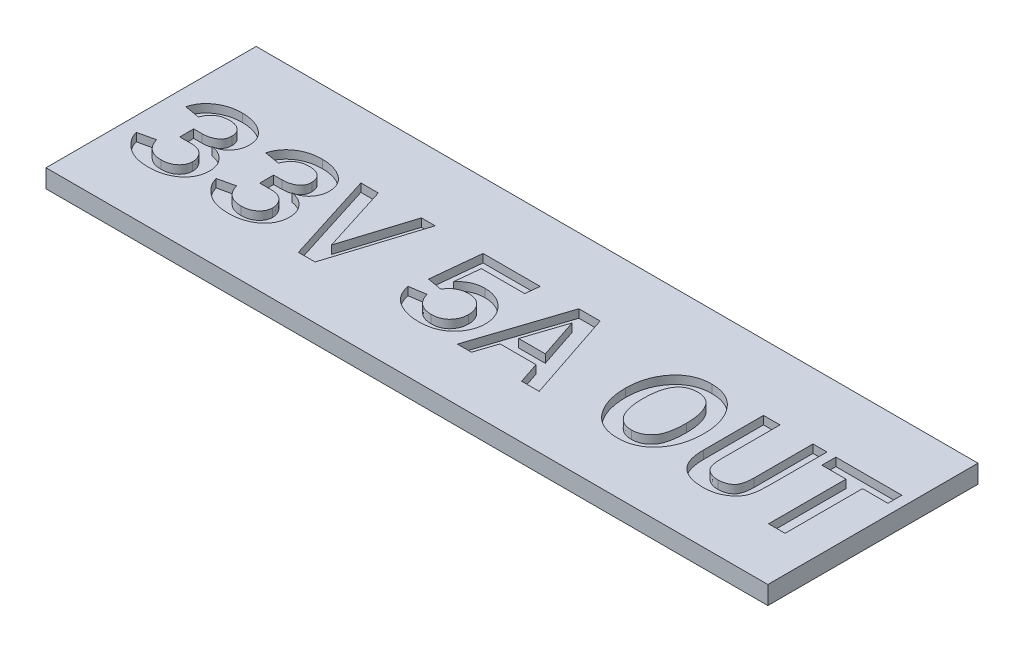
from build123d import *

# Parameters (mm, degrees)
SKETCH1_W           = 39.5
SKETCH1_H           = 11.5
BOSS_EXTRUDE1_DEPTH = 1
CUT_EXTRUDE1_DEPTH  = 0.45


with BuildPart() as part:
    # Sketch1 → Boss-Extrude1 (new body)
    with BuildSketch(Plane(origin=(0, 0, 0), x_dir=(1, 0, 0), z_dir=(0, 1, 0))):
        with Locations((6.224137931, 6.305172414)):
            Rectangle(SKETCH1_W, SKETCH1_H)
    extrude(amount=BOSS_EXTRUDE1_DEPTH)

    # Sketch2 → Cut-Extrude1 (cut)
    with BuildSketch(Plane(origin=(0, 1, 0), x_dir=(1, 0, 0), z_dir=(0, 1, 0))):
        with BuildLine():
            Line((-11.32600679, 5.673934363), (-11.32600679, 6.437823252))
            Line((-11.32600679, 6.437823252), (-10.877873109, 6.437823252))
            add(Edge.make_bspline(
                [(-10.877873109, 6.437823252), (-10.813316125, 6.439580263), (-10.689033154, 6.442962803), (-10.511370698, 6.477910683), (-10.349498962, 6.531465156), (-10.228160081, 6.595879397), (-10.142989777, 6.65863775), (-10.087086149, 6.710363239), (-10.040818181, 6.769236814), (-10.003182358, 6.832865086), (-9.973279085, 6.901728843), (-9.951278075, 6.975556434), (-9.939812107, 7.055593236), (-9.938032673, 7.110534094), (-9.937117901, 7.138778113)],
                knots=[0, 0, 0, 0, 0.000193447, 0.000372418, 0.000540897, 0.000703531, 0.000781874, 0.000857868, 0.000931244, 0.00100568, 0.001079057, 0.001155967, 0.001236071, 0.001320818, 0.001320818, 0.001320818, 0.001320818], degree=3))
            add(Edge.make_bspline(
                [(-9.937117901, 7.138778113), (-9.937606358, 7.166666113), (-9.93854931, 7.22050314), (-9.949700075, 7.298735949), (-9.968181506, 7.371382747), (-9.992913501, 7.439403529), (-10.025694734, 7.501871022), (-10.066276641, 7.558396604), (-10.113232361, 7.610255042), (-10.186752806, 7.670799996), (-10.291183551, 7.73529583), (-10.434049188, 7.787785268), (-10.592393334, 7.821357281), (-10.7037157, 7.824876734), (-10.761770679, 7.826712141)],
                knots=[0, 0, 0, 0, 8.3614e-05, 0.000161414, 0.000236417, 0.000308172, 0.000378064, 0.000447313, 0.000516435, 0.000587289, 0.000732445, 0.000882177, 0.001041782, 0.001215732, 0.001215732, 0.001215732, 0.001215732], degree=3))
            add(Edge.make_bspline(
                [(-10.761770679, 7.826712141), (-10.820523593, 7.824774438), (-10.934294399, 7.821022216), (-11.09756638, 7.788009334), (-11.246414463, 7.733502172), (-11.380688433, 7.656865866), (-11.499506359, 7.557227646), (-11.603368962, 7.436278146), (-11.692258586, 7.293328639), (-11.736903061, 7.187236761), (-11.760034568, 7.132267697)],
                knots=[0, 0, 0, 0, 0.000176116, 0.000341036, 0.000497244, 0.000649865, 0.000802409, 0.000960118, 0.001126318, 0.001305022, 0.001305022, 0.001305022, 0.001305022], degree=3))
            Line((-11.760034568, 7.132267697), (-12.593367901, 7.271156586))
            add(Edge.make_bspline(
                [(-12.593367901, 7.271156586), (-12.580924516, 7.316319519), (-12.556231345, 7.405942721), (-12.502741432, 7.534362043), (-12.440252067, 7.657634222), (-12.365123337, 7.773819618), (-12.278397759, 7.882957715), (-12.181327383, 7.986576931), (-12.072895052, 8.084464494), (-11.952569929, 8.173815214), (-11.823671725, 8.254820267), (-11.688176796, 8.327169913), (-11.544937247, 8.386290759), (-11.396600521, 8.436771695), (-11.241128455, 8.474655647), (-11.079721661, 8.501394743), (-10.911504591, 8.518227723), (-10.797256607, 8.520167301), (-10.738984221, 8.521156586)],
                knots=[0, 0, 0, 0, 0.000140411, 0.000278637, 0.000416458, 0.000554607, 0.000692889, 0.000834139, 0.000980121, 0.001130511, 0.00128314, 0.001436519, 0.001590683, 0.001747494, 0.001906185, 0.00207012, 0.002238011, 0.002412792, 0.002412792, 0.002412792, 0.002412792], degree=3))
            add(Edge.make_bspline(
                [(-10.738984221, 8.521156586), (-10.681061786, 8.520278505), (-10.567116267, 8.518551138), (-10.400107415, 8.500090016), (-10.239262493, 8.47364639), (-10.084892218, 8.434701979), (-9.937318247, 8.38303927), (-9.795169509, 8.322774447), (-9.660531869, 8.249380787), (-9.532913729, 8.16673651), (-9.416562715, 8.074522014), (-9.313973582, 7.973933298), (-9.227870492, 7.86474658), (-9.156773352, 7.74833047), (-9.101719075, 7.623895199), (-9.06321011, 7.492172024), (-9.038064175, 7.352767208), (-9.035601031, 7.25716317), (-9.034340123, 7.208222558)],
                knots=[0, 0, 0, 0, 0.000173696, 0.000341696, 0.000503491, 0.000662446, 0.000818579, 0.000972169, 0.001125102, 0.001277989, 0.001427792, 0.001569737, 0.001708018, 0.001843865, 0.001977944, 0.002114925, 0.002254781, 0.002401463, 0.002401463, 0.002401463, 0.002401463], degree=3))
            add(Edge.make_bspline(
                [(-9.034340123, 7.208222558), (-9.035105567, 7.171643279), (-9.036611165, 7.099693327), (-9.050518874, 6.994226183), (-9.070107526, 6.892501099), (-9.101685963, 6.795702048), (-9.138804006, 6.701631143), (-9.187348245, 6.612883061), (-9.242974677, 6.527427863), (-9.306481557, 6.446764652), (-9.376202464, 6.372705122), (-9.450645457, 6.306404104), (-9.530018735, 6.250403397), (-9.612482705, 6.202090932), (-9.699510432, 6.163614593), (-9.790542502, 6.134755091), (-9.885676015, 6.113461899), (-9.950762362, 6.106933328), (-9.983775887, 6.103621863)],
                knots=[0, 0, 0, 0, 0.000109678, 0.000215732, 0.000318728, 0.000419966, 0.000520714, 0.000621689, 0.00072281, 0.000826354, 0.000929212, 0.001027613, 0.001124865, 0.001220153, 0.00131391, 0.001409648, 0.001506274, 0.001605734, 0.001605734, 0.001605734, 0.001605734], degree=3))
            add(Edge.make_bspline(
                [(-9.983775887, 6.103621863), (-9.943867123, 6.096612871), (-9.865231813, 6.082802514), (-9.750841111, 6.052218917), (-9.64210303, 6.013454646), (-9.539953909, 5.965330027), (-9.443676971, 5.910057015), (-9.354130171, 5.845398988), (-9.270730406, 5.772299425), (-9.192515563, 5.692853406), (-9.123837617, 5.605929987), (-9.062178602, 5.515307356), (-9.009713891, 5.42008604), (-8.969018449, 5.319544098), (-8.935855955, 5.215514853), (-8.912237021, 5.107305692), (-8.897548759, 4.994363453), (-8.896159711, 4.917686936), (-8.895451234, 4.878578461)],
                knots=[0, 0, 0, 0, 0.000121513, 0.000239427, 0.000354751, 0.000467368, 0.000577731, 0.000687345, 0.000798096, 0.000910127, 0.001021292, 0.001129935, 0.001238702, 0.001346708, 0.001454808, 0.001565909, 0.001678558, 0.001795826, 0.001795826, 0.001795826, 0.001795826], degree=3))
            add(Edge.make_bspline(
                [(-8.895451234, 4.878578461), (-8.896660696, 4.825299019), (-8.899044256, 4.720297972), (-8.925363226, 4.566882779), (-8.964987654, 4.420330605), (-9.021809283, 4.28141984), (-9.095631702, 4.150615087), (-9.183558091, 4.025537886), (-9.290287125, 3.909805352), (-9.409839156, 3.800396775), (-9.5434914, 3.701607225), (-9.688979527, 3.615818505), (-9.84544895, 3.544632864), (-10.01117976, 3.48371972), (-10.188576016, 3.439547411), (-10.375819239, 3.405202964), (-10.574008939, 3.38589136), (-10.709647532, 3.383495193), (-10.77913179, 3.382267697)],
                knots=[0, 0, 0, 0, 0.000159686, 0.000314703, 0.000465543, 0.000614451, 0.00076358, 0.000915323, 0.001072032, 0.001234872, 0.001400891, 0.001569678, 0.001740572, 0.001915967, 0.002098611, 0.00228825, 0.002486696, 0.002695131, 0.002695131, 0.002695131, 0.002695131], degree=3))
            add(Edge.make_bspline(
                [(-10.77913179, 3.382267697), (-10.843553397, 3.383572431), (-10.969773025, 3.386128764), (-11.154829961, 3.404557365), (-11.331028756, 3.436181059), (-11.49895101, 3.479150852), (-11.65829769, 3.535994806), (-11.809116951, 3.605160723), (-11.951147733, 3.687413703), (-12.08398018, 3.780062775), (-12.205295198, 3.882061999), (-12.316922713, 3.987212523), (-12.415763867, 4.096994801), (-12.503125393, 4.210561522), (-12.57965208, 4.327246494), (-12.642163152, 4.448822503), (-12.696061779, 4.572555805), (-12.720202333, 4.658697662), (-12.73225679, 4.701712141)],
                knots=[0, 0, 0, 0, 0.000193252, 0.000378634, 0.000557209, 0.000729855, 0.000898023, 0.001064067, 0.001226918, 0.001389769, 0.001549259, 0.001701992, 0.001849506, 0.001991877, 0.002131527, 0.002267421, 0.002401637, 0.002535501, 0.002535501, 0.002535501, 0.002535501], degree=3))
            Line((-12.73225679, 4.701712141), (-11.829479012, 4.910045474))
            add(Edge.make_bspline(
                [(-11.829479012, 4.910045474), (-11.818693672, 4.876258727), (-11.797591049, 4.810151489), (-11.759394303, 4.715583127), (-11.717101302, 4.627446941), (-11.670564331, 4.545439413), (-11.618320866, 4.470494822), (-11.56168491, 4.402302128), (-11.501869191, 4.338975037), (-11.435470275, 4.284525774), (-11.365768414, 4.235051924), (-11.291379891, 4.192317497), (-11.212305397, 4.156988712), (-11.128973083, 4.127147011), (-11.041026443, 4.104648338), (-10.94817231, 4.088378008), (-10.850959267, 4.078542417), (-10.784579864, 4.077327968), (-10.750919984, 4.076712141)],
                knots=[0, 0, 0, 0, 0.00010637, 0.000208124, 0.000305672, 0.000399478, 0.000490682, 0.00057932, 0.000665267, 0.000751542, 0.000836434, 0.000921493, 0.00100842, 0.001095935, 0.001186731, 0.001280387, 0.001378531, 0.001479495, 0.001479495, 0.001479495, 0.001479495], degree=3))
            add(Edge.make_bspline(
                [(-10.750919984, 4.076712141), (-10.716172019, 4.077250797), (-10.647944125, 4.078308451), (-10.548437137, 4.089115365), (-10.454227953, 4.107938808), (-10.365213059, 4.132621267), (-10.280848754, 4.164282844), (-10.201522731, 4.202838711), (-10.12846371, 4.250538016), (-10.060171214, 4.303114362), (-9.999250072, 4.361346162), (-9.944628748, 4.422250507), (-9.901005528, 4.488217387), (-9.861926061, 4.554753182), (-9.833704901, 4.625884688), (-9.813000954, 4.699286907), (-9.800906995, 4.776187598), (-9.799130928, 4.828262479), (-9.798229012, 4.854706933)],
                knots=[0, 0, 0, 0, 0.000104218, 0.000204632, 0.000299754, 0.000392163, 0.000481443, 0.000569761, 0.000656145, 0.000742747, 0.000827944, 0.000908685, 0.000987537, 0.001064791, 0.001139747, 0.001216358, 0.001293245, 0.001372574, 0.001372574, 0.001372574, 0.001372574], degree=3))
            add(Edge.make_bspline(
                [(-9.798229012, 4.854706933), (-9.800741351, 4.907831278), (-9.80569991, 5.012681845), (-9.851359795, 5.163857361), (-9.924460817, 5.304479244), (-10.008233545, 5.410154361), (-10.08801946, 5.486818763), (-10.157121022, 5.536920108), (-10.233654524, 5.579432967), (-10.31751427, 5.613934344), (-10.408376282, 5.641113706), (-10.506409491, 5.660764486), (-10.61181517, 5.670985425), (-10.684349864, 5.672933375), (-10.721623109, 5.673934363)],
                knots=[0, 0, 0, 0, 0.000159047, 0.000313908, 0.000469209, 0.000632234, 0.000715897, 0.000800539, 0.000887487, 0.000977965, 0.001072023, 0.001171613, 0.001277422, 0.001389269, 0.001389269, 0.001389269, 0.001389269], degree=3))
            Line((-10.721623109, 5.673934363), (-11.32600679, 5.673934363))
        make_face()
        with BuildLine():
            Line((-6.95100679, 5.673934363), (-6.95100679, 6.437823252))
            Line((-6.95100679, 6.437823252), (-6.502873109, 6.437823252))
            add(Edge.make_bspline(
                [(-6.502873109, 6.437823252), (-6.438316125, 6.439580263), (-6.314033154, 6.442962803), (-6.136370698, 6.477910683), (-5.974498962, 6.531465156), (-5.853160081, 6.595879397), (-5.767989777, 6.65863775), (-5.712086149, 6.710363239), (-5.665818181, 6.769236814), (-5.628182358, 6.832865086), (-5.598279085, 6.901728843), (-5.576278075, 6.975556434), (-5.564812107, 7.055593236), (-5.563032673, 7.110534094), (-5.562117901, 7.138778113)],
                knots=[0, 0, 0, 0, 0.000193447, 0.000372418, 0.000540897, 0.000703531, 0.000781874, 0.000857868, 0.000931244, 0.00100568, 0.001079057, 0.001155967, 0.001236071, 0.001320818, 0.001320818, 0.001320818, 0.001320818], degree=3))
            add(Edge.make_bspline(
                [(-5.562117901, 7.138778113), (-5.562606358, 7.166666113), (-5.56354931, 7.22050314), (-5.574700075, 7.298735949), (-5.593181506, 7.371382747), (-5.617913501, 7.439403529), (-5.650694734, 7.501871022), (-5.691276641, 7.558396604), (-5.738232361, 7.610255042), (-5.811752806, 7.670799996), (-5.916183551, 7.73529583), (-6.059049188, 7.787785268), (-6.217393334, 7.821357281), (-6.3287157, 7.824876734), (-6.386770679, 7.826712141)],
                knots=[0, 0, 0, 0, 8.3614e-05, 0.000161414, 0.000236417, 0.000308172, 0.000378064, 0.000447313, 0.000516435, 0.000587289, 0.000732445, 0.000882177, 0.001041782, 0.001215732, 0.001215732, 0.001215732, 0.001215732], degree=3))
            add(Edge.make_bspline(
                [(-6.386770679, 7.826712141), (-6.445523593, 7.824774438), (-6.559294399, 7.821022216), (-6.72256638, 7.788009334), (-6.871414463, 7.733502172), (-7.005688433, 7.656865866), (-7.124506359, 7.557227646), (-7.228368962, 7.436278146), (-7.317258586, 7.293328639), (-7.361903061, 7.187236761), (-7.385034568, 7.132267697)],
                knots=[0, 0, 0, 0, 0.000176116, 0.000341036, 0.000497244, 0.000649865, 0.000802409, 0.000960118, 0.001126318, 0.001305022, 0.001305022, 0.001305022, 0.001305022], degree=3))
            Line((-7.385034568, 7.132267697), (-8.218367901, 7.271156586))
            add(Edge.make_bspline(
                [(-8.218367901, 7.271156586), (-8.205924516, 7.316319519), (-8.181231345, 7.405942721), (-8.127741432, 7.534362043), (-8.065252067, 7.657634222), (-7.990123337, 7.773819618), (-7.903397759, 7.882957715), (-7.806327383, 7.986576931), (-7.697895052, 8.084464494), (-7.577569929, 8.173815214), (-7.448671725, 8.254820267), (-7.313176796, 8.327169913), (-7.169937247, 8.386290759), (-7.021600521, 8.436771695), (-6.866128455, 8.474655647), (-6.704721661, 8.501394743), (-6.536504591, 8.518227723), (-6.422256607, 8.520167301), (-6.363984221, 8.521156586)],
                knots=[0, 0, 0, 0, 0.000140411, 0.000278637, 0.000416458, 0.000554607, 0.000692889, 0.000834139, 0.000980121, 0.001130511, 0.00128314, 0.001436519, 0.001590683, 0.001747494, 0.001906185, 0.00207012, 0.002238011, 0.002412792, 0.002412792, 0.002412792, 0.002412792], degree=3))
            add(Edge.make_bspline(
                [(-6.363984221, 8.521156586), (-6.306061786, 8.520278505), (-6.192116267, 8.518551138), (-6.025107415, 8.500090016), (-5.864262493, 8.47364639), (-5.709892218, 8.434701979), (-5.562318247, 8.38303927), (-5.420169509, 8.322774447), (-5.285531869, 8.249380787), (-5.157913729, 8.16673651), (-5.041562715, 8.074522014), (-4.938973582, 7.973933298), (-4.852870492, 7.86474658), (-4.781773352, 7.74833047), (-4.726719075, 7.623895199), (-4.68821011, 7.492172024), (-4.663064175, 7.352767208), (-4.660601031, 7.25716317), (-4.659340123, 7.208222558)],
                knots=[0, 0, 0, 0, 0.000173696, 0.000341696, 0.000503491, 0.000662446, 0.000818579, 0.000972169, 0.001125102, 0.001277989, 0.001427792, 0.001569737, 0.001708018, 0.001843865, 0.001977944, 0.002114925, 0.002254781, 0.002401463, 0.002401463, 0.002401463, 0.002401463], degree=3))
            add(Edge.make_bspline(
                [(-4.659340123, 7.208222558), (-4.660105567, 7.171643279), (-4.661611165, 7.099693327), (-4.675518874, 6.994226183), (-4.695107526, 6.892501099), (-4.726685963, 6.795702048), (-4.763804006, 6.701631143), (-4.812348245, 6.612883061), (-4.867974677, 6.527427863), (-4.931481557, 6.446764652), (-5.001202464, 6.372705122), (-5.075645457, 6.306404104), (-5.155018735, 6.250403397), (-5.237482705, 6.202090932), (-5.324510432, 6.163614593), (-5.415542502, 6.134755091), (-5.510676015, 6.113461899), (-5.575762362, 6.106933328), (-5.608775887, 6.103621863)],
                knots=[0, 0, 0, 0, 0.000109678, 0.000215732, 0.000318728, 0.000419966, 0.000520714, 0.000621689, 0.00072281, 0.000826354, 0.000929212, 0.001027613, 0.001124865, 0.001220153, 0.00131391, 0.001409648, 0.001506274, 0.001605734, 0.001605734, 0.001605734, 0.001605734], degree=3))
            add(Edge.make_bspline(
                [(-5.608775887, 6.103621863), (-5.568867123, 6.096612871), (-5.490231813, 6.082802514), (-5.375841111, 6.052218917), (-5.26710303, 6.013454646), (-5.164953909, 5.965330027), (-5.068676971, 5.910057015), (-4.979130171, 5.845398988), (-4.895730406, 5.772299425), (-4.817515563, 5.692853406), (-4.748837617, 5.605929987), (-4.687178602, 5.515307356), (-4.634713891, 5.42008604), (-4.594018449, 5.319544098), (-4.560855955, 5.215514853), (-4.537237021, 5.107305692), (-4.522548759, 4.994363453), (-4.521159711, 4.917686936), (-4.520451234, 4.878578461)],
                knots=[0, 0, 0, 0, 0.000121513, 0.000239427, 0.000354751, 0.000467368, 0.000577731, 0.000687345, 0.000798096, 0.000910127, 0.001021292, 0.001129935, 0.001238702, 0.001346708, 0.001454808, 0.001565909, 0.001678558, 0.001795826, 0.001795826, 0.001795826, 0.001795826], degree=3))
            add(Edge.make_bspline(
                [(-4.520451234, 4.878578461), (-4.521660696, 4.825299019), (-4.524044256, 4.720297972), (-4.550363226, 4.566882779), (-4.589987654, 4.420330605), (-4.646809283, 4.28141984), (-4.720631702, 4.150615087), (-4.808558091, 4.025537886), (-4.915287125, 3.909805352), (-5.034839156, 3.800396775), (-5.1684914, 3.701607225), (-5.313979527, 3.615818505), (-5.47044895, 3.544632864), (-5.63617976, 3.48371972), (-5.813576016, 3.439547411), (-6.000819239, 3.405202964), (-6.199008939, 3.38589136), (-6.334647532, 3.383495193), (-6.40413179, 3.382267697)],
                knots=[0, 0, 0, 0, 0.000159686, 0.000314703, 0.000465543, 0.000614451, 0.00076358, 0.000915323, 0.001072032, 0.001234872, 0.001400891, 0.001569678, 0.001740572, 0.001915967, 0.002098611, 0.00228825, 0.002486696, 0.002695131, 0.002695131, 0.002695131, 0.002695131], degree=3))
            add(Edge.make_bspline(
                [(-6.40413179, 3.382267697), (-6.468553397, 3.383572431), (-6.594773025, 3.386128764), (-6.779829961, 3.404557365), (-6.956028756, 3.436181059), (-7.12395101, 3.479150852), (-7.28329769, 3.535994806), (-7.434116951, 3.605160723), (-7.576147733, 3.687413703), (-7.70898018, 3.780062775), (-7.830295198, 3.882061999), (-7.941922713, 3.987212523), (-8.040763867, 4.096994801), (-8.128125393, 4.210561522), (-8.20465208, 4.327246494), (-8.267163152, 4.448822503), (-8.321061779, 4.572555805), (-8.345202333, 4.658697662), (-8.35725679, 4.701712141)],
                knots=[0, 0, 0, 0, 0.000193252, 0.000378634, 0.000557209, 0.000729855, 0.000898023, 0.001064067, 0.001226918, 0.001389769, 0.001549259, 0.001701992, 0.001849506, 0.001991877, 0.002131527, 0.002267421, 0.002401637, 0.002535501, 0.002535501, 0.002535501, 0.002535501], degree=3))
            Line((-8.35725679, 4.701712141), (-7.454479012, 4.910045474))
            add(Edge.make_bspline(
                [(-7.454479012, 4.910045474), (-7.443693672, 4.876258727), (-7.422591049, 4.810151489), (-7.384394303, 4.715583127), (-7.342101302, 4.627446941), (-7.295564331, 4.545439413), (-7.243320866, 4.470494822), (-7.18668491, 4.402302128), (-7.126869191, 4.338975037), (-7.060470275, 4.284525774), (-6.990768414, 4.235051924), (-6.916379891, 4.192317497), (-6.837305397, 4.156988712), (-6.753973083, 4.127147011), (-6.666026443, 4.104648338), (-6.57317231, 4.088378008), (-6.475959267, 4.078542417), (-6.409579864, 4.077327968), (-6.375919984, 4.076712141)],
                knots=[0, 0, 0, 0, 0.00010637, 0.000208124, 0.000305672, 0.000399478, 0.000490682, 0.00057932, 0.000665267, 0.000751542, 0.000836434, 0.000921493, 0.00100842, 0.001095935, 0.001186731, 0.001280387, 0.001378531, 0.001479495, 0.001479495, 0.001479495, 0.001479495], degree=3))
            add(Edge.make_bspline(
                [(-6.375919984, 4.076712141), (-6.341172019, 4.077250797), (-6.272944125, 4.078308451), (-6.173437137, 4.089115365), (-6.079227953, 4.107938808), (-5.990213059, 4.132621267), (-5.905848754, 4.164282844), (-5.826522731, 4.202838711), (-5.75346371, 4.250538016), (-5.685171214, 4.303114362), (-5.624250072, 4.361346162), (-5.569628748, 4.422250507), (-5.526005528, 4.488217387), (-5.486926061, 4.554753182), (-5.458704901, 4.625884688), (-5.438000954, 4.699286907), (-5.425906995, 4.776187598), (-5.424130928, 4.828262479), (-5.423229012, 4.854706933)],
                knots=[0, 0, 0, 0, 0.000104218, 0.000204632, 0.000299754, 0.000392163, 0.000481443, 0.000569761, 0.000656145, 0.000742747, 0.000827944, 0.000908685, 0.000987537, 0.001064791, 0.001139747, 0.001216358, 0.001293245, 0.001372574, 0.001372574, 0.001372574, 0.001372574], degree=3))
            add(Edge.make_bspline(
                [(-5.423229012, 4.854706933), (-5.425741351, 4.907831278), (-5.43069991, 5.012681845), (-5.476359795, 5.163857361), (-5.549460817, 5.304479244), (-5.633233545, 5.410154361), (-5.71301946, 5.486818763), (-5.782121022, 5.536920108), (-5.858654524, 5.579432967), (-5.94251427, 5.613934344), (-6.033376282, 5.641113706), (-6.131409491, 5.660764486), (-6.23681517, 5.670985425), (-6.309349864, 5.672933375), (-6.346623109, 5.673934363)],
                knots=[0, 0, 0, 0, 0.000159047, 0.000313908, 0.000469209, 0.000632234, 0.000715897, 0.000800539, 0.000887487, 0.000977965, 0.001072023, 0.001171613, 0.001277422, 0.001389269, 0.001389269, 0.001389269, 0.001389269], degree=3))
            Line((-6.346623109, 5.673934363), (-6.95100679, 5.673934363))
        make_face()
        Polygon((-1.696015471, 3.451712141), (-2.611814082, 3.451712141), (-4.190590123, 8.451712141), (-3.237899151, 8.451712141), (-2.055173457, 4.706052419), (-0.880043248, 8.451712141), (-0.128090123, 8.451712141), align=None)
        with BuildLine():
            Line((2.493437654, 8.451712141), (5.618437654, 8.451712141))
            Line((5.618437654, 8.451712141), (5.538142516, 7.687823252))
            Line((5.538142516, 7.687823252), (3.167265779, 7.687823252))
            Line((3.167265779, 7.687823252), (3.024036613, 6.300019433))
            add(Edge.make_bspline(
                [(3.024036613, 6.300019433), (3.061794846, 6.344305593), (3.135966884, 6.43130105), (3.261637999, 6.544690901), (3.396425201, 6.639801191), (3.538972568, 6.718365844), (3.690372058, 6.779999742), (3.850398166, 6.822835591), (4.018856807, 6.849807374), (4.13395859, 6.85290847), (4.192656404, 6.854489919)],
                knots=[0, 0, 0, 0, 0.000174453, 0.000342695, 0.00050617, 0.000668369, 0.000829968, 0.000995273, 0.00116439, 0.001340386, 0.001340386, 0.001340386, 0.001340386], degree=3))
            add(Edge.make_bspline(
                [(4.192656404, 6.854489919), (4.251320017, 6.853048234), (4.366930924, 6.850207043), (4.53679418, 6.827208325), (4.699216584, 6.78800131), (4.854451216, 6.733408738), (5.002688227, 6.663474809), (5.144627483, 6.578786355), (5.278460023, 6.47677365), (5.403863217, 6.361462345), (5.519737393, 6.237143903), (5.619709752, 6.10396307), (5.705317097, 5.965480843), (5.774862079, 5.820632867), (5.829394758, 5.67014038), (5.868858282, 5.513937352), (5.891895278, 5.351637963), (5.89476381, 5.241425964), (5.896215432, 5.185653113)],
                knots=[0, 0, 0, 0, 0.000175945, 0.000346743, 0.00051307, 0.000676423, 0.000839516, 0.001004017, 0.001171336, 0.001343374, 0.001514612, 0.001680411, 0.00184213, 0.002002284, 0.002161549, 0.002321555, 0.002484828, 0.002652102, 0.002652102, 0.002652102, 0.002652102], degree=3))
            add(Edge.make_bspline(
                [(5.896215432, 5.185653113), (5.894997624, 5.127679223), (5.892588288, 5.012982443), (5.866105409, 4.844515542), (5.826740614, 4.681244326), (5.768361409, 4.524919871), (5.695592048, 4.374130644), (5.605728368, 4.229754879), (5.498844697, 4.092303074), (5.377874299, 3.961313443), (5.243575551, 3.840677036), (5.093757813, 3.737277493), (4.933609939, 3.647733275), (4.75997344, 3.576251633), (4.575265971, 3.519140119), (4.377196678, 3.481646427), (4.168054673, 3.455114391), (4.024198361, 3.452862756), (3.950685918, 3.451712141)],
                knots=[0, 0, 0, 0, 0.000173777, 0.000343804, 0.00051039, 0.000676887, 0.000843342, 0.001011958, 0.001186019, 0.001364924, 0.001546316, 0.001726323, 0.001909915, 0.002095712, 0.00228861, 0.002488855, 0.002699755, 0.002920155, 0.002920155, 0.002920155, 0.002920155], degree=3))
            add(Edge.make_bspline(
                [(3.950685918, 3.451712141), (3.891705148, 3.452867476), (3.774995548, 3.455153621), (3.602656309, 3.469895754), (3.436393908, 3.497434202), (3.275924904, 3.534652341), (3.120209509, 3.58058317), (2.970791957, 3.639695246), (2.826614562, 3.708169994), (2.689154926, 3.787086288), (2.559081203, 3.87639347), (2.441943571, 3.980266875), (2.336079149, 4.094702519), (2.241689853, 4.220544957), (2.160616048, 4.358835249), (2.091262089, 4.508738729), (2.031518694, 4.669495364), (2.004013273, 4.782755627), (1.989965432, 4.84060103)],
                knots=[0, 0, 0, 0, 0.00017695, 0.000350143, 0.00051836, 0.000682076, 0.000844105, 0.0010049, 0.001163606, 0.001322553, 0.001479982, 0.001636054, 0.001791162, 0.001946978, 0.002107018, 0.002271093, 0.002442039, 0.002620483, 0.002620483, 0.002620483, 0.002620483], degree=3))
            Line((1.989965432, 4.84060103), (2.89274321, 4.979489919))
            add(Edge.make_bspline(
                [(2.89274321, 4.979489919), (2.915180428, 4.913649716), (2.958260598, 4.78723444), (3.04936652, 4.616039363), (3.157241224, 4.470175637), (3.283711169, 4.351184262), (3.427510894, 4.25771114), (3.58934782, 4.192992361), (3.768247356, 4.152735026), (3.893313137, 4.148405603), (3.958281404, 4.146156586)],
                knots=[0, 0, 0, 0, 0.000208404, 0.000400142, 0.000579179, 0.000750362, 0.000918306, 0.001090586, 0.001270655, 0.001465319, 0.001465319, 0.001465319, 0.001465319], degree=3))
            add(Edge.make_bspline(
                [(3.958281404, 4.146156586), (3.998468702, 4.14688019), (4.076936418, 4.148293063), (4.191079449, 4.162461727), (4.298111362, 4.186607645), (4.397989531, 4.21857464), (4.490689544, 4.260635322), (4.576703552, 4.311305598), (4.655043043, 4.372624548), (4.725916282, 4.442290458), (4.787706384, 4.519360893), (4.843809008, 4.599128157), (4.889729912, 4.684200209), (4.927476946, 4.772482142), (4.957060566, 4.86515004), (4.979054911, 4.961238657), (4.9906475, 5.061670552), (4.992499616, 5.129565202), (4.993437654, 5.163951724)],
                knots=[0, 0, 0, 0, 0.000120521, 0.000235323, 0.000344306, 0.000449306, 0.000549345, 0.000649088, 0.000748062, 0.000847041, 0.000946519, 0.001044037, 0.001139208, 0.00123595, 0.001331688, 0.001430668, 0.001531205, 0.001634378, 0.001634378, 0.001634378, 0.001634378], degree=3))
            add(Edge.make_bspline(
                [(4.993437654, 5.163951724), (4.9926624, 5.198359945), (4.991138767, 5.265983522), (4.977399996, 5.365016012), (4.957217594, 5.459959856), (4.927804313, 5.55105401), (4.888395235, 5.637551163), (4.841559167, 5.720331166), (4.787158578, 5.799471932), (4.723239301, 5.872358098), (4.653268419, 5.939323888), (4.577947302, 5.998666075), (4.49732024, 6.048450751), (4.412216779, 6.090361561), (4.321477398, 6.122039573), (4.225197185, 6.142883778), (4.124410081, 6.158044977), (4.055273771, 6.159371285), (4.020130363, 6.160045474)],
                knots=[0, 0, 0, 0, 0.000103173, 0.000202769, 0.000299395, 0.000394101, 0.000489291, 0.000584041, 0.000679156, 0.000776842, 0.000874312, 0.000969384, 0.001063928, 0.001158073, 0.001253473, 0.001351394, 0.001453287, 0.001558628, 0.001558628, 0.001558628, 0.001558628], degree=3))
            add(Edge.make_bspline(
                [(4.020130363, 6.160045474), (3.967207959, 6.158477673), (3.863944759, 6.155418549), (3.714086397, 6.128662153), (3.574077184, 6.085673444), (3.444289783, 6.023776422), (3.324034343, 5.94515024), (3.213753518, 5.848823037), (3.11391278, 5.734544814), (3.057400444, 5.648619408), (3.028376891, 5.604489919)],
                knots=[0, 0, 0, 0, 0.000158658, 0.000309576, 0.000455089, 0.000596814, 0.000739466, 0.000884821, 0.001034769, 0.001193089, 0.001193089, 0.001193089, 0.001193089], degree=3))
            Line((3.028376891, 5.604489919), (2.215659877, 5.743378808))
            Line((2.215659877, 5.743378808), (2.493437654, 8.451712141))
        make_face()
        Polygon((10.566354321, 3.451712141), (9.603897724, 3.451712141), (9.211102585, 4.632267697), (7.246041821, 4.632267697), (6.856501891, 3.451712141), (6.087187654, 3.451712141), (7.735408141, 8.451712141), (8.899687654, 8.451712141), align=None)
        Polygon((8.955026196, 5.396156586), (8.222604321, 7.59450728), (7.496692863, 5.396156586), align=None, mode=Mode.SUBTRACT)
        with BuildLine():
            add(Edge.make_bspline(
                [(14.903376891, 3.382267697), (14.821497666, 3.384497197), (14.66167534, 3.388849021), (14.429286063, 3.424597459), (14.210112102, 3.480932546), (14.006232837, 3.565154423), (13.814458288, 3.668700828), (13.638753899, 3.798963925), (13.475722026, 3.950528706), (13.329324604, 4.125359578), (13.199358137, 4.317276406), (13.083477765, 4.520285443), (12.9866104, 4.735033833), (12.908888055, 4.960902339), (12.846727177, 5.196938458), (12.802275774, 5.444321502), (12.776092585, 5.702660619), (12.77285871, 5.878590354), (12.771215432, 5.967988183)],
                knots=[0, 0, 0, 0, 0.000245516, 0.000479229, 0.000703734, 0.000922759, 0.001139342, 0.001355935, 0.001577039, 0.001805721, 0.002038366, 0.002271606, 0.002506167, 0.002743975, 0.002987423, 0.003237719, 0.003497275, 0.003765428, 0.003765428, 0.003765428, 0.003765428], degree=3))
            add(Edge.make_bspline(
                [(12.771215432, 5.967988183), (12.773205006, 6.057030796), (12.777104634, 6.231557231), (12.804367682, 6.487806143), (12.850636356, 6.73294959), (12.917483556, 6.966766041), (13.000611787, 7.190074047), (13.10311486, 7.402070511), (13.225425659, 7.602209095), (13.364268115, 7.790132386), (13.518478448, 7.961273411), (13.686467931, 8.111532001), (13.867469081, 8.237708149), (14.059864454, 8.341929282), (14.264294487, 8.422517819), (14.480457977, 8.480250123), (14.708807203, 8.514069783), (14.864924913, 8.518761744), (14.944609529, 8.521156586)],
                knots=[0, 0, 0, 0, 0.000267106, 0.000523536, 0.000772095, 0.001014593, 0.001252206, 0.001486118, 0.001719849, 0.001954879, 0.002186111, 0.002409764, 0.002629506, 0.002846522, 0.00306474, 0.003287148, 0.003516408, 0.003755422, 0.003755422, 0.003755422, 0.003755422], degree=3))
            add(Edge.make_bspline(
                [(14.944609529, 8.521156586), (15.024651073, 8.51874463), (15.181479367, 8.514018798), (15.410271871, 8.480536336), (15.625996283, 8.422430077), (15.828899279, 8.342392261), (16.018405166, 8.237893891), (16.195206238, 8.111350223), (16.358897482, 7.9614461), (16.507577396, 7.789863994), (16.641587402, 7.601947081), (16.757643735, 7.400226116), (16.857027097, 7.188085816), (16.937434662, 6.963852403), (17.00043187, 6.728322724), (17.04412033, 6.481071556), (17.072380325, 6.222913804), (17.07528788, 6.046913207), (17.076770988, 5.957137488)],
                knots=[0, 0, 0, 0, 0.000240097, 0.000470431, 0.000691791, 0.000909, 0.001123157, 0.001339356, 0.001559785, 0.001787412, 0.002019252, 0.002251147, 0.002484641, 0.002721129, 0.002964855, 0.003215151, 0.003473739, 0.003742976, 0.003742976, 0.003742976, 0.003742976], degree=3))
            add(Edge.make_bspline(
                [(17.076770988, 5.957137488), (17.074791694, 5.863036627), (17.070931166, 5.679496858), (17.043871007, 5.410930961), (16.997176096, 5.156251757), (16.932555656, 4.915013307), (16.848806799, 4.687358808), (16.745192241, 4.474481597), (16.624647191, 4.274211149), (16.484943394, 4.090502759), (16.330282059, 3.924857527), (16.163271695, 3.778890767), (15.983819189, 3.65525803), (15.790374942, 3.556280749), (15.586126043, 3.477536543), (15.369019718, 3.422611825), (15.14032505, 3.387854602), (14.983439332, 3.384155457), (14.903376891, 3.382267697)],
                knots=[0, 0, 0, 0, 0.000282287, 0.000550589, 0.000808747, 0.001058275, 0.001298938, 0.001535276, 0.001767517, 0.001999074, 0.002226313, 0.002446285, 0.002663282, 0.002878271, 0.003096713, 0.003318569, 0.003548903, 0.003788949, 0.003788949, 0.003788949, 0.003788949], degree=3))
        make_face()
        with BuildLine():
            add(Edge.make_bspline(
                [(14.913142516, 4.146156586), (14.954089924, 4.147424357), (15.034599045, 4.149916996), (15.152765353, 4.169147325), (15.266593742, 4.19909267), (15.374913026, 4.243255056), (15.479804399, 4.297457699), (15.577857574, 4.366573041), (15.672194151, 4.4465452), (15.762126142, 4.539019118), (15.844606542, 4.648537802), (15.915070846, 4.777966572), (15.973241039, 4.927757236), (16.021345772, 5.096735906), (16.059078753, 5.285794175), (16.085426306, 5.494280859), (16.101792638, 5.722862303), (16.103604611, 5.881876374), (16.104548766, 5.964732974)],
                knots=[0, 0, 0, 0, 0.000122786, 0.000241416, 0.000358282, 0.000475147, 0.000591634, 0.000711729, 0.000834131, 0.000962284, 0.001097918, 0.001244096, 0.001402873, 0.001579045, 0.001770565, 0.001980657, 0.002209103, 0.002457643, 0.002457643, 0.002457643, 0.002457643], degree=3))
            add(Edge.make_bspline(
                [(16.104548766, 5.964732974), (16.103726825, 6.032748653), (16.102125073, 6.165293723), (16.089399565, 6.358419867), (16.066472532, 6.540218622), (16.035499671, 6.710641752), (15.995216185, 6.869765216), (15.947128434, 7.017873189), (15.887998436, 7.154116676), (15.821215256, 7.279098373), (15.745430941, 7.392235836), (15.658644188, 7.490156521), (15.561537739, 7.573130922), (15.454772923, 7.640594569), (15.337835676, 7.693207305), (15.211411338, 7.731439179), (15.074460436, 7.752858128), (14.980128156, 7.755769583), (14.931588696, 7.757267697)],
                knots=[0, 0, 0, 0, 0.000204039, 0.00039762, 0.000580254, 0.000753491, 0.00091692, 0.001072357, 0.001220106, 0.001361869, 0.001496998, 0.001627658, 0.001753118, 0.001878949, 0.002005209, 0.002136682, 0.002274041, 0.002419638, 0.002419638, 0.002419638, 0.002419638], degree=3))
            add(Edge.make_bspline(
                [(14.931588696, 7.757267697), (14.88341864, 7.755688812), (14.789876805, 7.752622762), (14.654143793, 7.732370631), (14.528155445, 7.696098798), (14.411182053, 7.646297756), (14.303637519, 7.581410424), (14.205330179, 7.502443991), (14.115656134, 7.409992354), (14.037467284, 7.30190238), (13.967629994, 7.180461408), (13.907335651, 7.044726132), (13.856399696, 6.894623288), (13.814470715, 6.731027399), (13.781920949, 6.553002964), (13.760076949, 6.360859585), (13.745387291, 6.154486856), (13.744101255, 6.01214195), (13.743437654, 5.938691308)],
                knots=[0, 0, 0, 0, 0.000144514, 0.000280633, 0.000410452, 0.000536829, 0.000660949, 0.00078601, 0.000914164, 0.001046114, 0.001185143, 0.001333766, 0.001490925, 0.001660147, 0.001839984, 0.002033388, 0.002240034, 0.002460345, 0.002460345, 0.002460345, 0.002460345], degree=3))
            add(Edge.make_bspline(
                [(13.743437654, 5.938691308), (13.744140613, 5.867413902), (13.745505201, 5.729049633), (13.759708928, 5.528361969), (13.783251064, 5.340626069), (13.816773653, 5.166330577), (13.858406284, 5.004975874), (13.910802728, 4.857232642), (13.972301668, 4.722738006), (14.042642217, 4.600995421), (14.123384982, 4.49439971), (14.211587758, 4.401257095), (14.30790127, 4.322033465), (14.413046619, 4.257416412), (14.526681171, 4.20750381), (14.648308129, 4.171161294), (14.778278464, 4.15088929), (14.867502228, 4.147758213), (14.913142516, 4.146156586)],
                knots=[0, 0, 0, 0, 0.000213803, 0.000415036, 0.000603188, 0.000781093, 0.000947165, 0.001102634, 0.001250717, 0.001390291, 0.001523538, 0.00165094, 0.001774314, 0.00189658, 0.002019973, 0.002145626, 0.002276385, 0.002413314, 0.002413314, 0.002413314, 0.002413314], degree=3))
        make_face(mode=Mode.SUBTRACT)
        with BuildLine():
            Line((21.312882099, 8.451712141), (21.312882099, 5.244246863))
            add(Edge.make_bspline(
                [(21.312882099, 5.244246863), (21.312460593, 5.191435425), (21.311643222, 5.0890252), (21.305504345, 4.940225728), (21.293331983, 4.800912479), (21.277397613, 4.670914757), (21.25683209, 4.549952412), (21.232074852, 4.438354848), (21.203376261, 4.335784), (21.16789154, 4.242436181), (21.127483972, 4.154264197), (21.077048683, 4.071312253), (21.019488264, 3.990384196), (20.952879848, 3.91317349), (20.877373326, 3.839243603), (20.793932915, 3.767931798), (20.702239533, 3.698865951), (20.60192688, 3.634789222), (20.495137643, 3.57422707), (20.380630641, 3.524589931), (20.262288572, 3.478386232), (20.136400711, 3.445034772), (20.005544006, 3.416017623), (19.868358592, 3.397223648), (19.726014573, 3.384853801), (19.629243382, 3.383139552), (19.580026196, 3.382267697)],
                knots=[0, 0, 0, 0, 0.000158435, 0.000307232, 0.000446633, 0.000577854, 0.000700049, 0.000814564, 0.000920684, 0.001019235, 0.001113891, 0.001211215, 0.00130998, 0.001411549, 0.001516666, 0.001626709, 0.001740641, 0.001860731, 0.001983617, 0.002108443, 0.002234806, 0.002364329, 0.00249862, 0.002636726, 0.002779371, 0.002927004, 0.002927004, 0.002927004, 0.002927004], degree=3))
            add(Edge.make_bspline(
                [(19.580026196, 3.382267697), (19.530445144, 3.382715978), (19.433327938, 3.383594052), (19.291158528, 3.39565137), (19.154958859, 3.410352882), (19.026326747, 3.436386175), (18.903799966, 3.465921507), (18.788666101, 3.504296118), (18.679831307, 3.548718449), (18.577640357, 3.59943581), (18.482943058, 3.657393187), (18.395131429, 3.720505323), (18.3131454, 3.787485283), (18.239028493, 3.860794053), (18.171923203, 3.939083021), (18.110442035, 4.021576887), (18.057355987, 4.110200792), (18.010491897, 4.203765161), (17.9703414, 4.303330858), (17.935691425, 4.408835771), (17.906201145, 4.521149622), (17.883213721, 4.640173393), (17.862746834, 4.765230169), (17.85086837, 4.89722082), (17.841209197, 5.035409591), (17.840845197, 5.129933599), (17.840659877, 5.178057627)],
                knots=[0, 0, 0, 0, 0.00014869, 0.000291248, 0.000427855, 0.000559367, 0.000684635, 0.00080576, 0.000923033, 0.001037069, 0.001147608, 0.001255707, 0.001361294, 0.001464877, 0.001567975, 0.00167041, 0.001773131, 0.001877461, 0.001984052, 0.002094884, 0.002210422, 0.002332143, 0.002458446, 0.002590383, 0.002729543, 0.002873873, 0.002873873, 0.002873873, 0.002873873], degree=3))
            Line((17.840659877, 5.178057627), (17.840659877, 8.451712141))
            Line((17.840659877, 8.451712141), (18.743437654, 8.451712141))
            Line((18.743437654, 8.451712141), (18.743437654, 5.224715613))
            add(Edge.make_bspline(
                [(18.743437654, 5.224715613), (18.744159599, 5.17187513), (18.74554163, 5.070721738), (18.758955296, 4.926145873), (18.778703112, 4.795364706), (18.807661951, 4.678544167), (18.845393713, 4.575656588), (18.891578704, 4.486639986), (18.94781, 4.412546103), (19.032205772, 4.333286622), (19.151869491, 4.258736925), (19.305907276, 4.193887621), (19.470889082, 4.153148246), (19.584855991, 4.148517499), (19.642960224, 4.146156586)],
                knots=[0, 0, 0, 0, 0.00015848, 0.00030338, 0.00043521, 0.000554952, 0.00066379, 0.000763297, 0.000854662, 0.000941393, 0.001109337, 0.001274186, 0.001441568, 0.001615667, 0.001615667, 0.001615667, 0.001615667], degree=3))
            add(Edge.make_bspline(
                [(19.642960224, 4.146156586), (19.67626873, 4.146659499), (19.741625562, 4.147646298), (19.837009174, 4.158965868), (19.927372578, 4.176120289), (20.012925148, 4.199862214), (20.093058879, 4.231523681), (20.16874869, 4.269295746), (20.238123485, 4.315451662), (20.303476565, 4.36747514), (20.362106958, 4.430670175), (20.413421675, 4.506110446), (20.455358365, 4.595351158), (20.489695637, 4.696630658), (20.516697306, 4.81070442), (20.535934107, 4.937328278), (20.546158115, 5.076979058), (20.548021188, 5.174063617), (20.54899321, 5.224715613)],
                knots=[0, 0, 0, 0, 9.9879e-05, 0.00019598, 0.000287699, 0.000375636, 0.000461877, 0.000545828, 0.000628891, 0.000711421, 0.000795875, 0.000886464, 0.000984011, 0.001090729, 0.001206791, 0.001335238, 0.00147455, 0.001626522, 0.001626522, 0.001626522, 0.001626522], degree=3))
            Line((20.54899321, 5.224715613), (20.54899321, 8.451712141))
            Line((20.54899321, 8.451712141), (21.312882099, 8.451712141))
        make_face()
        Polygon((24.021215432, 3.451712141), (23.118437654, 3.451712141), (23.118437654, 7.687823252), (21.79899321, 7.687823252), (21.79899321, 8.451712141), (25.410104321, 8.451712141), (25.410104321, 7.687823252), (24.021215432, 7.687823252), align=None)
    extrude(amount=-CUT_EXTRUDE1_DEPTH, mode=Mode.SUBTRACT)


solid = part.part
